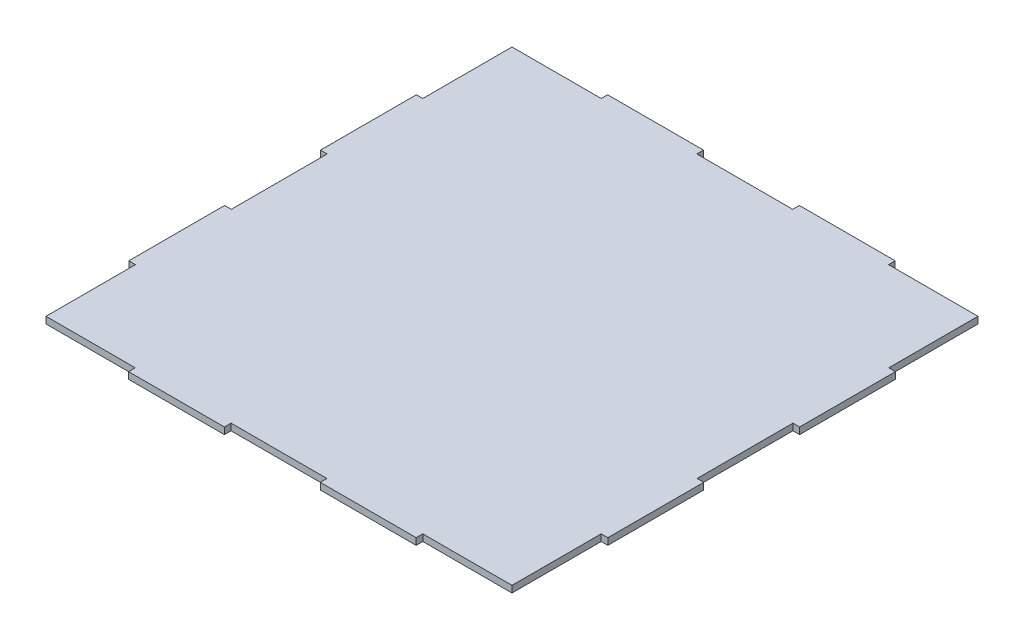
from build123d import *

# Parameters (mm, degrees)
SKETCH1_W           = 228.6
SKETCH1_H           = 228.6
BOSS_EXTRUDE1_DEPTH = 3.175
SKETCH3_W           = 45.72
SKETCH3_H           = 3.175
SKETCH3_W_2         = 3.175
SKETCH3_H_2         = 45.72
CUT_EXTRUDE1_DEPTH  = 6.35


with BuildPart() as part:
    # Sketch1 → Boss-Extrude1 (new body)
    with BuildSketch(Plane(origin=(0, 0, 0), x_dir=(1, 0, 0), z_dir=(0, 1, 0))):
        Rectangle(SKETCH1_W, SKETCH1_H)
    extrude(amount=BOSS_EXTRUDE1_DEPTH)

    # Sketch3 → Cut-Extrude1 (cut)
    with BuildSketch(Plane(origin=(0, 3.175, 0), x_dir=(1, 0, 0), z_dir=(0, 1, 0))):
        Polygon((-111.125, -111.125), (-68.58, -111.125), (-68.58, -114.3), (-114.3, -114.3), (-114.3, -68.47527879), (-111.125, -68.47527879), align=None)
        with Locations((0, -112.7125)):
            Rectangle(SKETCH3_W, SKETCH3_H)
        Polygon((68.47527879, 111.125), (111.125, 111.125), (111.125, 68.58), (114.3, 68.58), (114.3, 114.3), (68.47527879, 114.3), align=None)
        with Locations((-112.7125, 0.10472121)):
            Rectangle(SKETCH3_W_2, SKETCH3_H_2)
        Polygon((-111.22972121, 111.22972121), (-111.22972121, 68.68472121), (-114.40472121, 68.68472121), (-114.404601278, 114.40472121), (-68.68472121, 114.3), (-68.68472121, 111.22972121), align=None)
        Polygon((111.125, -111.125), (111.125, -68.58), (114.3, -68.58), (114.3, -114.3), (68.58, -114.3), (68.58, -111.125), align=None)
        with Locations((112.7125, 0)):
            Rectangle(SKETCH3_W_2, SKETCH3_H_2)
        with Locations((-0.10472121, 112.7125)):
            Rectangle(SKETCH3_W, SKETCH3_H)
    extrude(amount=-CUT_EXTRUDE1_DEPTH, mode=Mode.SUBTRACT)


solid = part.part
